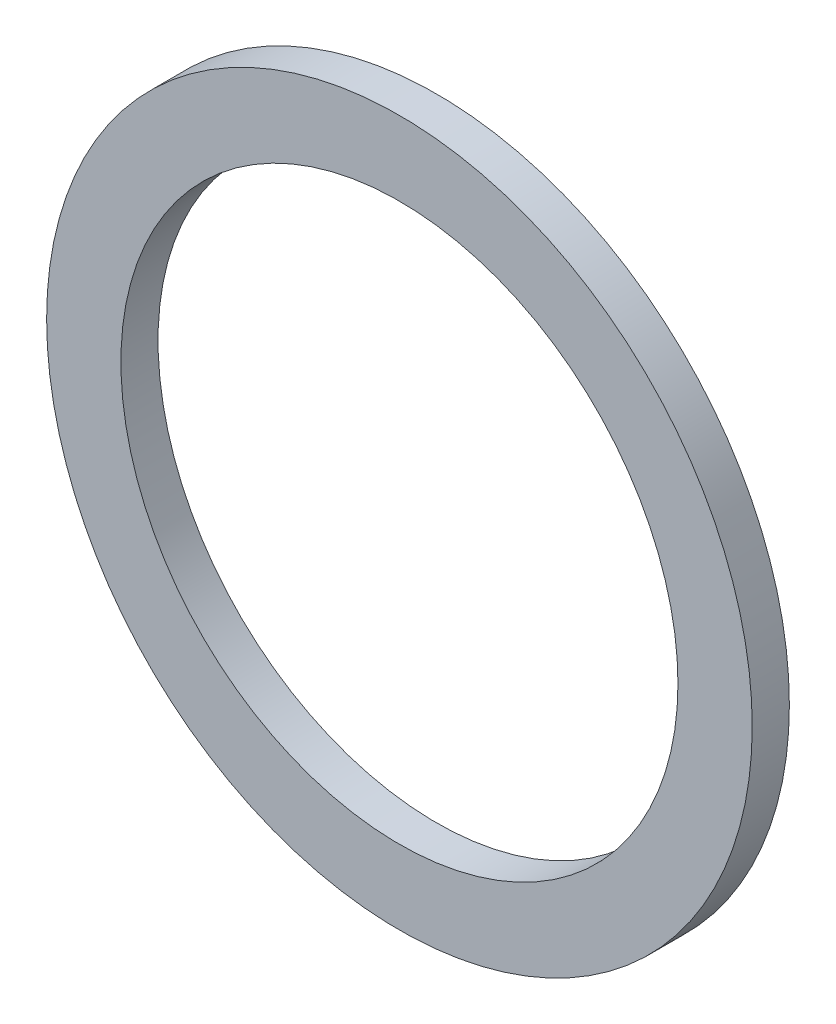
from build123d import *

# Parameters (mm, degrees)
SKETCH_1_W = 2
SKETCH_1_H = 1


with BuildPart() as part:
    # Эскиз1 → Повернуть1 (revolve)
    with BuildSketch(Plane(origin=(0, 0, 0), x_dir=(1, 0, 0), z_dir=(0, 1, 0))):
        with Locations((-8.5, 0.5)):
            Rectangle(SKETCH_1_W, SKETCH_1_H)
    revolve(axis=Axis((0, 0, 0), (0, 0, -1)))


solid = part.part
